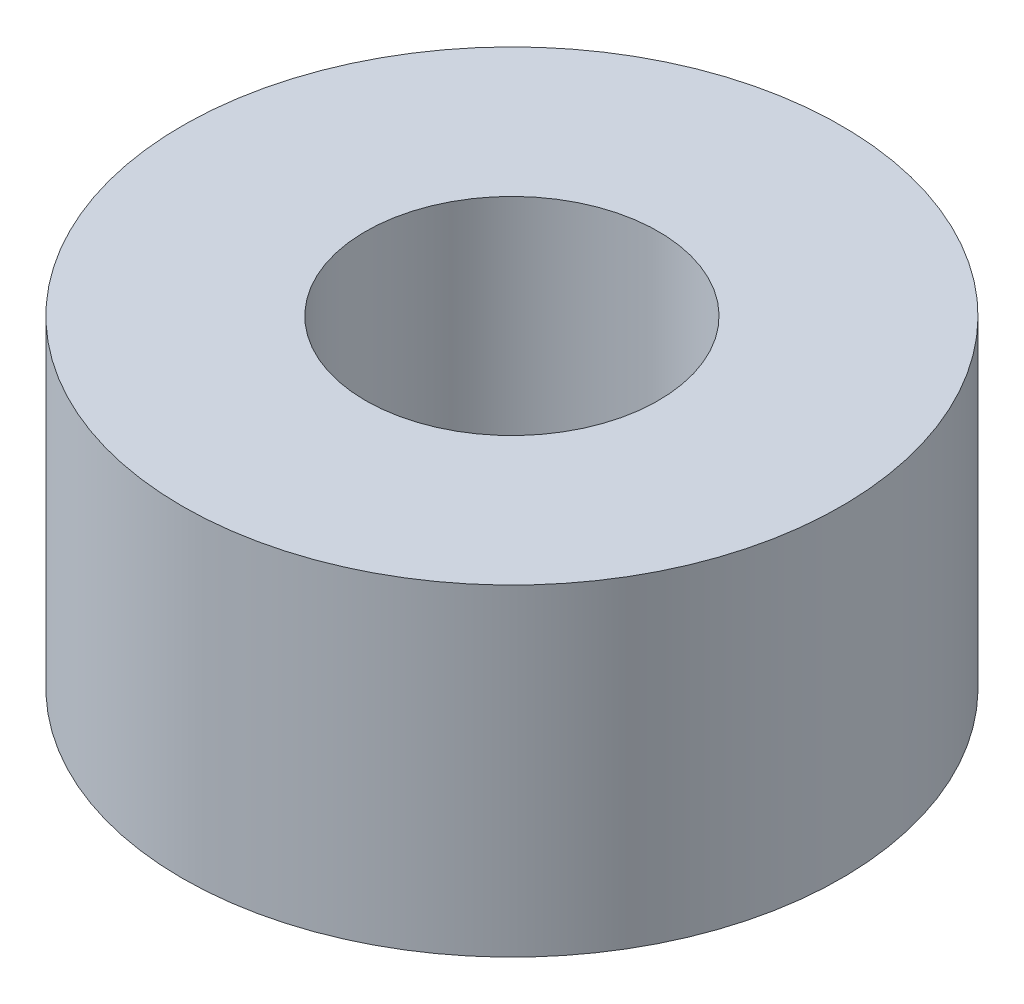
from build123d import *

# Parameters (mm, degrees)
SKETCH1_R           = 5.715
SKETCH1_R_2         = 2.54
BOSS_EXTRUDE1_DEPTH = 5.588


with BuildPart() as part:
    # Sketch1 → Boss-Extrude1 (new body)
    with BuildSketch(Plane(origin=(0, 0, 0), x_dir=(1, 0, 0), z_dir=(0, 1, 0))):
        Circle(SKETCH1_R)
        Circle(SKETCH1_R_2, mode=Mode.SUBTRACT)
    extrude(amount=BOSS_EXTRUDE1_DEPTH)


solid = part.part
